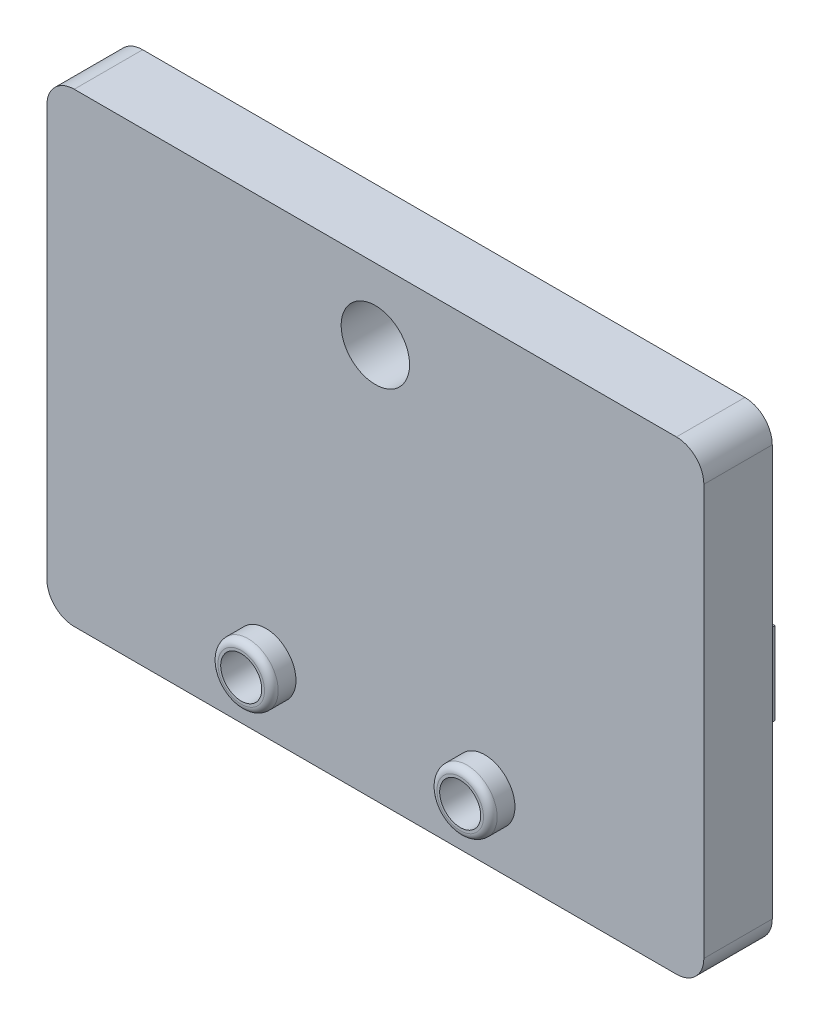
from build123d import *

# Parameters (mm, degrees)
BOSS_EXTRUDE5_DEPTH       = 5
SKETCH9_R                 = 2.2
SKETCH9_R_2               = 1.5
BOSS_EXTRUDE11_DEPTH      = 1.8
BOSS_EXTRUDE11_DEPTH_BACK = 5
SKETCH9_10_R              = 1.5
CUT_EXTRUDE4_DEPTH        = 6
SKETCH11_R                = 2.5
CUT_EXTRUDE5_DEPTH        = 7.8
SKETCH12_W                = 6
SKETCH12_H                = 6
BOSS_EXTRUDE12_DEPTH      = 5
FILLET7_R                 = 0.5


with BuildPart() as part:
    # Sketch8 → Boss-Extrude5 (new body)
    with BuildSketch(Plane.XY):
        with BuildLine():
            Line((-33.540427797, 119.803578872), (10.459572203, 119.803578872))
            ThreePointArc((10.459572203, 119.803578872), (11.873785765, 119.217792435), (12.459572203, 117.803578872))
            Line((12.459572203, 117.803578872), (12.459572203, 87.803578872))
            ThreePointArc((12.459572203, 87.803578872), (11.873785765, 86.38936531), (10.459572203, 85.803578872))
            Line((10.459572203, 85.803578872), (-33.540427797, 85.803578872))
            ThreePointArc((-33.540427797, 85.803578872), (-34.95464136, 86.38936531), (-35.540427797, 87.803578872))
            Line((-35.540427797, 87.803578872), (-35.540427797, 117.803578872))
            ThreePointArc((-35.540427797, 117.803578872), (-34.95464136, 119.217792435), (-33.540427797, 119.803578872))
        make_face()
    extrude(amount=BOSS_EXTRUDE5_DEPTH)

    # Sketch9 → Boss-Extrude11 (add, two sides)
    with BuildSketch(Plane.XY.offset(5)) as boss_extrude11_sk:
        with Locations((-3.540427797, 90.491289859)):
            Circle(SKETCH9_R)
        with Locations((-3.540427797, 90.491289859)):
            Circle(SKETCH9_R_2, mode=Mode.SUBTRACT)
        with Locations((-19.540427797, 90.491289859)):
            Circle(SKETCH9_R)
        with Locations((-19.540427797, 90.491289859)):
            Circle(SKETCH9_R_2, mode=Mode.SUBTRACT)
    extrude(amount=BOSS_EXTRUDE11_DEPTH)
    extrude(boss_extrude11_sk.sketch, amount=-BOSS_EXTRUDE11_DEPTH_BACK)

    # Sketch9_10 → Cut-Extrude4 (cut, through all)
    with BuildSketch(Plane.XY.offset(5)):
        with Locations((-3.540427797, 90.491289859)):
            Circle(SKETCH9_10_R)
        with Locations((-19.540427797, 90.491289859)):
            Circle(SKETCH9_10_R)
    extrude(amount=-CUT_EXTRUDE4_DEPTH, mode=Mode.SUBTRACT)

    # Sketch11 → Cut-Extrude5 (cut, through all)
    with BuildSketch(Plane(origin=(0, 0, 0), x_dir=(-1, 0, 0), z_dir=(0, 0, -1))):
        with Locations((11.540427797, 114.618963942)):
            Circle(SKETCH11_R)
    extrude(amount=-CUT_EXTRUDE5_DEPTH, mode=Mode.SUBTRACT)

    # Sketch12 → Boss-Extrude12 (add)
    with BuildSketch(Plane(origin=(0, 0, 0), x_dir=(-1, 0, 0), z_dir=(0, 0, -1))):
        with Locations((-4.669308543, 98.468963942)):
            Rectangle(SKETCH12_W, SKETCH12_H)
        with Locations((26.892367502, 98.468963942)):
            Rectangle(SKETCH12_W, SKETCH12_H)
    extrude(amount=BOSS_EXTRUDE12_DEPTH)

    # Fillet7
    fillet7_edges = [part.edges().sort_by_distance(p)[0] for p in [
        (-21.740427797, 90.491289859, 6.8),
        (-5.740427797, 90.491289859, 6.8),
    ]]
    fillet(fillet7_edges, radius=FILLET7_R)


solid = part.part
